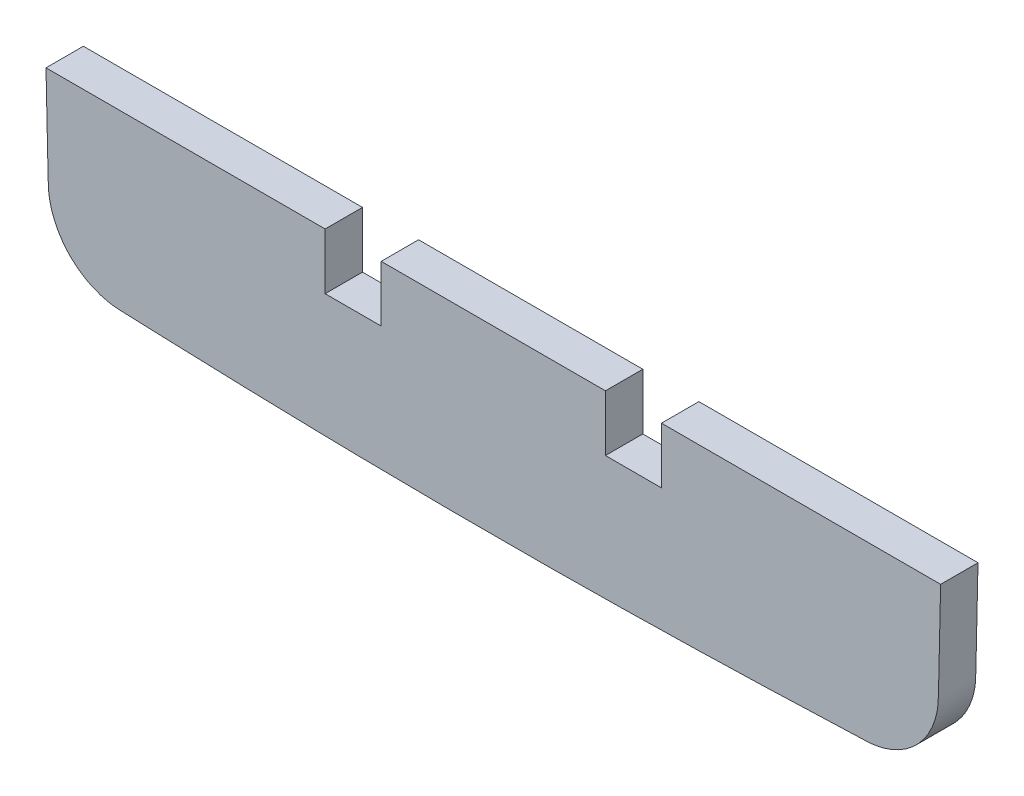
from build123d import *

# Parameters (mm, degrees)
BOSS_EXTRUDE1_DEPTH = 5.08


with BuildPart() as part:
    # Sketch1 → Boss-Extrude1 (new body)
    with BuildSketch(Plane.XY):
        with BuildLine():
            Line((40.64, -38.1), (2.699896737, -38.1))
            add(Edge.make_bspline(
                [(124.300123963, -38.1), (124.287236378, -38.753536376), (124.274193084, -39.400375447), (124.261017522, -40.040518664), (124.212053837, -42.419451058), (124.161237565, -44.705936197), (124.109602291, -46.90016707), (124.083784653, -47.997282506), (124.057759681, -49.071334776), (124.03164179, -50.122350094), (124.018582844, -50.647857753), (124.00685427, -51.167389184), (123.992371149, -51.681604769), (123.985129589, -51.938712561), (123.968112085, -52.19592455), (123.941510909, -52.452225629), (123.928210321, -52.580376168), (123.912513899, -52.708300014), (123.885412302, -52.899664601), (123.875785614, -52.963365996), (123.860460992, -53.058765812), (123.855205353, -53.090540374), (123.847101331, -53.13816143), (123.84436323, -53.154028317), (123.84020101, -53.177818113), (123.838804426, -53.18574629), (123.836695791, -53.197635878), (123.83599062, -53.201598628), (123.834575693, -53.209523229), (123.834078677, -53.212301526), (123.83315389, -53.217446479), (123.714781185, -53.876000446), (123.531903392, -54.528452396), (123.036555362, -55.789579355), (122.723377399, -56.398272756), (121.98499373, -57.541744747), (121.559861933, -58.076523122), (120.616202925, -59.043818357), (120.097678269, -59.476339969), (118.999459827, -60.226749088), (118.419764547, -60.544621041), (117.229627485, -61.054311169), (116.619187477, -61.246539051), (116.007782981, -61.379674402), (115.702080733, -61.446242077), (115.396123747, -61.498034695), (114.787140539, -61.572928101), (114.484498501, -61.593601496), (114.184150678, -61.605653891), (113.583455031, -61.629758681), (112.986190205, -61.653427009), (112.392325067, -61.676659229), (110.016864517, -61.769588106), (107.695771112, -61.855530159), (105.427280343, -61.934582469), (104.293034959, -61.974108623), (103.171945824, -62.011914166), (102.063824351, -62.048021597), (101.509763614, -62.066075313), (100.958944745, -62.083704438), (100.41134798, -62.100913262), (100.137549597, -62.109517674), (99.864556799, -62.118017035), (99.592367287, -62.126411943), (99.456272531, -62.130609397), (99.320378597, -62.134780738), (99.116838507, -62.140998696), (99.049041946, -62.143064839), (98.947422255, -62.146154305), (98.913561549, -62.147182502), (98.862789273, -62.148722363), (98.845868311, -62.149235243), (98.820491562, -62.150003956), (98.812033428, -62.150260092), (98.795118725, -62.150772162), (98.788262443, -62.150979678), (98.778206369, -62.151283927), (93.629496513, -62.307059391), (88.626933593, -62.429381017), (83.759023305, -62.518663556), (81.325068161, -62.563304825), (78.924865761, -62.59974537), (76.557367753, -62.628234842), (75.373618748, -62.642479578), (74.198048907, -62.654736356), (73.030543438, -62.665056512), (72.446790703, -62.67021659), (71.865054235, -62.674892584), (71.285320713, -62.679091174), (70.995453953, -62.68119047), (70.706087939, -62.683170416), (70.417221071, -62.685031861), (70.272787638, -62.685962583), (70.128478991, -62.686863681), (69.912202906, -62.688171049), (69.840142026, -62.688599459), (69.696082512, -62.689441546), (69.625410024, -62.689847736), (69.552116344, -62.690261548), (67.20671857, -62.70350353), (64.834114379, -62.709263058), (60.042762202, -62.70448621), (57.627439102, -62.693994984), (52.755512824, -62.656371126), (50.298909301, -62.629224585), (47.820546129, -62.593613245), (46.581364543, -62.575807575), (45.336741314, -62.555891423), (44.086524502, -62.533864622), (43.461416096, -62.522851222), (42.834909159, -62.511310213), (42.206983866, -62.4992419), (41.893021219, -62.493207744), (41.578703975, -62.487041765), (41.264029603, -62.480744023), (41.106692417, -62.477595152), (40.949265948, -62.47441334), (40.712991841, -62.469591224), (40.634211405, -62.467975619), (40.51600709, -62.465539864), (40.476600041, -62.464725887), (40.417481045, -62.463501836), (40.397773309, -62.463093304), (40.358355029, -62.462275212), (40.336529749, -62.461821658), (40.318932534, -62.461455577), (35.814045676, -62.367738784), (31.135589788, -62.244860451), (26.273484312, -62.090978142), (23.842431574, -62.014036987), (21.36542288, -61.929359948), (18.840543979, -61.836969352), (17.578104528, -61.790774054), (16.303691519, -61.742652555), (15.017030975, -61.692619983), (14.373700703, -61.667603697), (13.727308185, -61.642109771), (13.077816954, -61.616140875), (12.915444146, -61.609648651), (12.753061313, -61.604435176), (12.426912804, -61.586929426), (12.263100353, -61.574071405), (11.934529022, -61.54002886), (11.769770141, -61.518844336), (11.522324561, -61.480734819), (11.439791544, -61.466976184), (11.315966083, -61.444743991), (11.27468661, -61.437067552), (11.212767302, -61.425152949), (11.192127516, -61.421114756), (11.161168613, -61.414957308), (11.150849107, -61.412888132), (11.130210488, -61.408716364), (11.118027517, -61.406230969), (11.109572524, -61.404494459), (10.568452961, -61.293357841), (10.025174669, -61.13567514), (8.95472284, -60.72005469), (8.427554014, -60.461164804), (7.411730862, -59.845164203), (6.923071248, -59.488345338), (6.008787131, -58.683982358), (5.583987845, -58.235636732), (5.201259624, -57.748647381), (4.435803181, -56.77466868), (3.83876838, -55.647173162), (3.468827937, -54.455413744), (3.283857716, -53.859534035), (3.153587759, -53.247820747), (3.078845154, -52.633028911), (3.041473851, -52.325632993), (3.017982452, -52.017486164), (2.998942487, -51.403108157), (2.992690852, -51.095241056), (2.984922881, -50.785937836), (2.922779114, -48.31151208), (2.862379731, -45.760807851), (2.804756722, -43.133682501), (2.775945218, -41.820119825), (2.747830008, -40.487452377), (2.720553795, -39.13566552), (2.713612928, -38.791681775), (2.70672648, -38.446459959), (2.699896737, -38.1)],
                knots=[0.347176115, 0.347176115, 0.347176115, 0.347176115, 0.347826087, 0.347826087, 0.347826087, 0.352657005, 0.352657005, 0.352657005, 0.357487923, 0.357487923, 0.357487923, 0.362318841, 0.362318841, 0.362318841, 0.367149758, 0.367149758, 0.367149758, 0.371980676, 0.371980676, 0.376811594, 0.376811594, 0.381642512, 0.381642512, 0.38647343, 0.38647343, 0.391304348, 0.391304348, 0.396135266, 0.396135266, 0.400966184, 0.400966184, 0.400966184, 0.405797101, 0.405797101, 0.410628019, 0.410628019, 0.415458937, 0.415458937, 0.420289855, 0.420289855, 0.425120773, 0.425120773, 0.429951691, 0.429951691, 0.429951691, 0.434782609, 0.434782609, 0.439613527, 0.439613527, 0.439613527, 0.444444444, 0.444444444, 0.444444444, 0.449275362, 0.449275362, 0.449275362, 0.45410628, 0.45410628, 0.45410628, 0.458937198, 0.458937198, 0.458937198, 0.463768116, 0.463768116, 0.463768116, 0.468599034, 0.468599034, 0.473429952, 0.473429952, 0.47826087, 0.47826087, 0.483091787, 0.483091787, 0.487922705, 0.487922705, 0.492753623, 0.492753623, 0.492753623, 0.497584541, 0.497584541, 0.497584541, 0.502415459, 0.502415459, 0.502415459, 0.507246377, 0.507246377, 0.507246377, 0.512077295, 0.512077295, 0.512077295, 0.516908213, 0.516908213, 0.516908213, 0.52173913, 0.52173913, 0.526570048, 0.526570048, 0.531400966, 0.531400966, 0.531400966, 0.536231884, 0.536231884, 0.541062802, 0.541062802, 0.54589372, 0.54589372, 0.54589372, 0.550724638, 0.550724638, 0.550724638, 0.555555556, 0.555555556, 0.555555556, 0.560386473, 0.560386473, 0.560386473, 0.565217391, 0.565217391, 0.570048309, 0.570048309, 0.574879227, 0.574879227, 0.579710145, 0.579710145, 0.584541063, 0.584541063, 0.584541063, 0.589371981, 0.589371981, 0.589371981, 0.594202899, 0.594202899, 0.594202899, 0.599033816, 0.599033816, 0.599033816, 0.603864734, 0.603864734, 0.603864734, 0.608695652, 0.608695652, 0.61352657, 0.61352657, 0.618357488, 0.618357488, 0.623188406, 0.623188406, 0.628019324, 0.628019324, 0.632850242, 0.632850242, 0.637681159, 0.637681159, 0.642512077, 0.642512077, 0.642512077, 0.647342995, 0.647342995, 0.652173913, 0.652173913, 0.657004831, 0.657004831, 0.661835749, 0.661835749, 0.661835749, 0.666666667, 0.666666667, 0.666666667, 0.671497585, 0.671497585, 0.671497585, 0.676328502, 0.676328502, 0.68115942, 0.68115942, 0.68115942, 0.685990338, 0.685990338, 0.685990338, 0.690821256, 0.690821256, 0.690821256, 0.693279864, 0.693279864, 0.693279864, 0.693279864], degree=3))
            Line((124.300123963, -38.1), (86.36, -38.1))
            Line((86.36, -38.1), (86.36, -45.72))
            Line((86.36, -45.72), (78.74, -45.72))
            Line((78.74, -45.72), (78.74, -38.1))
            Line((78.74, -38.1), (48.26, -38.1))
            Line((48.26, -38.1), (48.26, -45.72))
            Line((48.26, -45.72), (40.64, -45.72))
            Line((40.64, -45.72), (40.64, -38.1))
        make_face()
    extrude(amount=BOSS_EXTRUDE1_DEPTH)


solid = part.part
